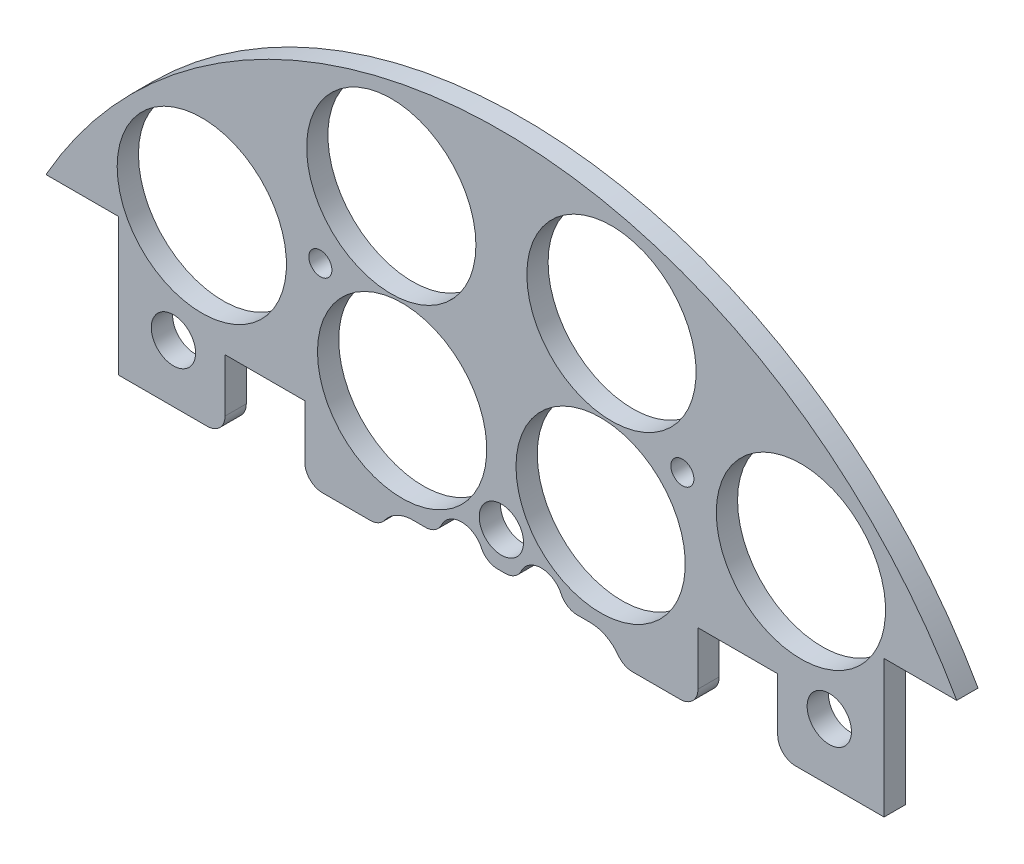
from build123d import *

# Parameters (mm, degrees)
SKETCH1_R                 = 1.651
BOSS_EXTRUDE2_DEPTH       = 3.048
SKETCH2_R                 = 1.143
CUT_EXTRUDE1_DEPTH        = 4.048
SKETCH3_R                 = 12.1285
CUT_EXTRUDE2_DEPTH        = 4.048
SKETCH4_W                 = 28.562713242
SKETCH4_H                 = 11.677503754
BOSS_EXTRUDE3_DEPTH       = 3.048
SKETCH5_W                 = 230.699333954
SKETCH5_H                 = 107.587024537
CUT_EXTRUDE3_DEPTH        = 4.048
SKETCH6_R                 = 12.1285
CUT_EXTRUDE4_DEPTH        = 4.048
SKETCH9_W                 = 11.43
SKETCH9_H                 = 10.16
CUT_EXTRUDE7_DEPTH        = 4.048
SKETCH65_R                = 1.651
CUT_EXTRUDE63_DEPTH       = 97.79
SKETCH119_R               = 3.175
CUT_EXTRUDE117_DEPTH      = 103.378
CUT_EXTRUDE117_DEPTH_BACK = 48.768
CUT_EXTRUDE10_DEPTH       = 14.224
FILLET1_R                 = 2.54


with BuildPart() as part:
    # Sketch1 → Boss-Extrude2 (new body)
    with BuildSketch(Plane.XY):
        with BuildLine():
            Line((-65.2537815, 36.83), (-54.8397815, 36.83))
            Line((-54.8397815, 36.83), (-54.8397815, -36.83))
            Line((-54.8397815, -36.83), (-65.2537815, -36.83))
            ThreePointArc((-65.2537815, -36.83), (0, -74.93), (65.2537815, -36.83))
            Line((65.2537815, -36.83), (54.8397815, -36.83))
            Line((54.8397815, -36.83), (54.8397815, 36.83))
            Line((54.8397815, 36.83), (65.2537815, 36.83))
            ThreePointArc((65.2537815, 36.83), (0, 74.93), (-65.2537815, 36.83))
        make_face()
        with Locations((-45.466, 11.049)):
            Circle(SKETCH1_R, mode=Mode.SUBTRACT)
        with Locations((-20.067270032, 10.795)):
            Circle(SKETCH1_R, mode=Mode.SUBTRACT)
        with Locations((-20.067270032, -10.795)):
            Circle(SKETCH1_R, mode=Mode.SUBTRACT)
        with Locations((-45.466, -11.049)):
            Circle(SKETCH1_R, mode=Mode.SUBTRACT)
        with Locations((45.466, -11.049)):
            Circle(SKETCH1_R, mode=Mode.SUBTRACT)
        with Locations((20.067270032, -10.795)):
            Circle(SKETCH1_R, mode=Mode.SUBTRACT)
        with Locations((20.067270032, 10.795)):
            Circle(SKETCH1_R, mode=Mode.SUBTRACT)
        with Locations((45.466, 11.049)):
            Circle(SKETCH1_R, mode=Mode.SUBTRACT)
    extrude(amount=BOSS_EXTRUDE2_DEPTH)

    # Sketch2 → Cut-Extrude1 (cut, through all)
    with BuildSketch(Plane.XY.offset(3.048)):
        with Locations((-6.731, 62.23)):
            Circle(SKETCH2_R)
        with Locations((6.731, 62.23)):
            Circle(SKETCH2_R)
    extrude(amount=-CUT_EXTRUDE1_DEPTH, mode=Mode.SUBTRACT)

    # Sketch3 → Cut-Extrude2 (cut, through all)
    with BuildSketch(Plane(origin=(0, 0, 0), x_dir=(-1, 0, 0), z_dir=(0, 0, -1))):
        with Locations((-42.926, -42.926)):
            Circle(SKETCH3_R)
        with Locations((-14.224, 34.29)):
            Circle(SKETCH3_R)
        with Locations((14.224, -34.29)):
            Circle(SKETCH3_R)
        with Locations((14.224, 34.29)):
            Circle(SKETCH3_R)
        with Locations((-42.926, 42.926)):
            Circle(SKETCH3_R)
        with Locations((42.926, 42.926)):
            Circle(SKETCH3_R)
        with Locations((-14.224, -34.29)):
            Circle(SKETCH3_R)
        with Locations((42.926, -42.926)):
            Circle(SKETCH3_R)
    extrude(amount=-CUT_EXTRUDE2_DEPTH, mode=Mode.SUBTRACT)

    # Sketch4 → Boss-Extrude3 (add)
    with BuildSketch(Plane(origin=(0, 0, 0), x_dir=(-1, 0, 0), z_dir=(0, 0, -1))):
        with Locations((-1.488809975, 62.152540216)):
            Rectangle(SKETCH4_W, SKETCH4_H)
    extrude(amount=-BOSS_EXTRUDE3_DEPTH)

    # Sketch5 → Cut-Extrude3 (cut, through all)
    with BuildSketch(Plane(origin=(0, 0, 0), x_dir=(-1, 0, 0), z_dir=(0, 0, -1))):
        with Locations((1.971047261, -36.648512269)):
            Rectangle(SKETCH5_W, SKETCH5_H)
    extrude(amount=-CUT_EXTRUDE3_DEPTH, mode=Mode.SUBTRACT)

    # Sketch6 → Cut-Extrude4 (cut, through all)
    with BuildSketch(Plane(origin=(0, 0, 0), x_dir=(-1, 0, 0), z_dir=(0, 0, -1))):
        with Locations((-15.777608989, 58.882838371)):
            Circle(SKETCH6_R)
        with Locations((15.777608989, 58.882838371)):
            Circle(SKETCH6_R)
    extrude(amount=-CUT_EXTRUDE4_DEPTH, mode=Mode.SUBTRACT)

    # Sketch9 → Cut-Extrude7 (cut, through all)
    with BuildSketch(Plane(origin=(0, 0, 0), x_dir=(-1, 0, 0), z_dir=(0, 0, -1))):
        with Locations((33.8847815, 22.225)):
            Rectangle(SKETCH9_W, SKETCH9_H)
        with Locations((-33.8847815, 22.225)):
            Rectangle(SKETCH9_W, SKETCH9_H)
    extrude(amount=-CUT_EXTRUDE7_DEPTH, mode=Mode.SUBTRACT)

    # Sketch65 → Cut-Extrude63 (cut)
    with BuildSketch(Plane(origin=(30.092005081, 4.08352975, -16.1925), x_dir=(-1, 0, 0), z_dir=(0, 0, -1))):
        with Locations((4.154396091, 41.38247025)):
            Circle(SKETCH65_R)
        with Locations((56.02961407, 41.38247025)):
            Circle(SKETCH65_R)
    extrude(amount=-CUT_EXTRUDE63_DEPTH, mode=Mode.SUBTRACT)

    # Sketch119 → Cut-Extrude117 (cut, two sides)
    with BuildSketch(Plane(origin=(30.092005081, 4.08352975, 19.939), x_dir=(-1, 0, 0), z_dir=(0, 0, -1))) as cut_extrude117_sk:
        with Locations((-16.897994919, 21.31647025)):
            Circle(SKETCH119_R)
        with Locations((77.082005081, 21.31647025)):
            Circle(SKETCH119_R)
        with Locations((30.092005081, 21.31647025)):
            Circle(SKETCH119_R)
    extrude(amount=CUT_EXTRUDE117_DEPTH, mode=Mode.SUBTRACT)
    extrude(cut_extrude117_sk.sketch, amount=-CUT_EXTRUDE117_DEPTH_BACK, mode=Mode.SUBTRACT)

    # Sketch12 → Cut-Extrude10 (cut)
    with BuildSketch(Plane(origin=(0, 0, 0), x_dir=(-1, 0, 0), z_dir=(0, 0, -1))):
        with BuildLine():
            Line((12.7, 20.24), (8.888991966, 20.24))
            ThreePointArc((8.888991966, 20.24), (5.715, 23.495), (2.541008034, 20.24))
            Line((2.541008034, 20.24), (-2.541008034, 20.24))
            ThreePointArc((-2.541008034, 20.24), (-5.715, 23.495), (-8.888991966, 20.24))
            Line((-8.888991966, 20.24), (-12.7, 20.24))
            ThreePointArc((-12.7, 20.24), (-16.235533906, 11.704466094), (-7.7, 15.24))
            Line((-7.7, 15.24), (7.7, 15.24))
            ThreePointArc((7.7, 15.24), (16.235533906, 11.704466094), (12.7, 20.24))
        make_face()
    extrude(amount=-CUT_EXTRUDE10_DEPTH, mode=Mode.SUBTRACT)

    # Fillet1
    fillet1_edges = [part.edges().sort_by_distance(p)[0] for p in [
        (-39.5997815, 17.145, 1.524),
        (-28.1697815, 17.145, 1.524),
        (28.1697815, 17.145, 1.524),
        (39.5997815, 17.145, 1.524),
        (-17.322875188, 17.145, 1.524),
        (17.322875188, 17.145, 1.524),
        (8.888991966, 20.24, 1.524),
        (2.541008034, 20.24, 1.524),
        (-2.541008034, 20.24, 1.524),
        (-8.888991966, 20.24, 1.524),
    ]]
    fillet(fillet1_edges, radius=FILLET1_R)


solid = part.part
